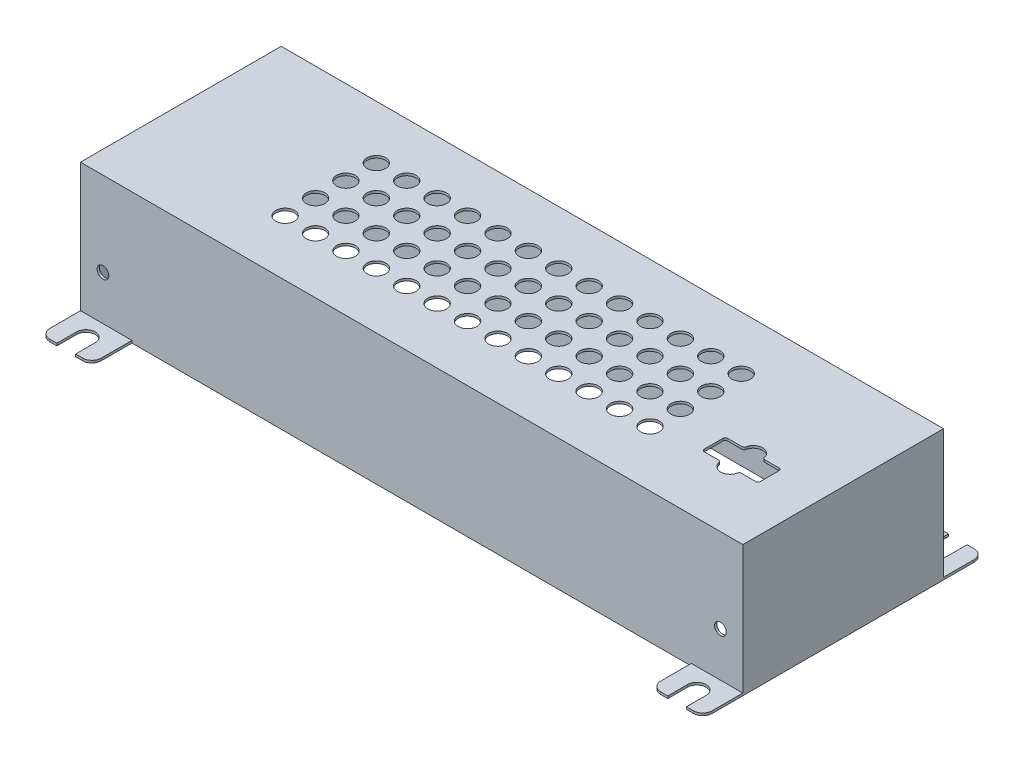
from build123d import *

# Parameters (mm, degrees)
SCHIZZO1_W                   = 141.6
SCHIZZO1_H                   = 42.9
ESTRUSIONE_ESTRUSIONE1_DEPTH = 28
SVUOTA1_T                    = -0.5
RIPETIZIONE_A_L1_COUNT       = 13
RIPETIZIONE_A_L1_PITCH       = 6.5
RIPETIZIONE_A_L1_COUNT_DIR2  = 4
RIPETIZIONE_A_L1_PITCH_DIR2  = 6.5
SCHIZZO4_W                   = 12
SCHIZZO4_H                   = 5
TAGLIO_ESTRUSIONE1_DEPTH     = 28
TAGLIO_ESTRUSIONE2_DEPTH     = 28
SCHIZZO8_W                   = 11
SCHIZZO8_H                   = 8.55
ESTRUSIONE_ESTRUSIONE2_DEPTH = 0.5
TAGLIO_ESTRUSIONE3_DEPTH     = 10
RIPETIZIONE_A_L2_COUNT       = 2
RIPETIZIONE_A_L2_PITCH       = 130.6
FORO_FILETTATO_M3X0_5_1_D    = 2.5
RACCORDO2_R                  = 2
RACCORDO3_R                  = 0.5


with BuildPart() as part:
    # Schizzo1 → Estrusione-Estrusione1 (new body)
    with BuildSketch(Plane(origin=(0, 0, 0), x_dir=(1, 0, 0), z_dir=(0, 1, 0))):
        Rectangle(SCHIZZO1_W, SCHIZZO1_H)
    extrude(amount=ESTRUSIONE_ESTRUSIONE1_DEPTH)

    # Svuota1
    svuota1_openings = [part.faces().sort_by_distance(p)[0] for p in [
        (0, 0, 0),
    ]]
    offset(amount=SVUOTA1_T, openings=svuota1_openings, kind=Kind.INTERSECTION)

    # Schizzo2 → Foro Ø4.0 (4)-1 (revolve, cut)
    with BuildSketch(Plane(origin=(-39, 28, -10), x_dir=(0, 0, 1), z_dir=(1, 0, 0))):
        Polygon((0, 0), (0, 7.201721238), (2, 6), (2, 0), align=None)
    foro_4_0_4_1 = revolve(axis=Axis((-39, 34.35, -10), (0, -1, 0)), mode=Mode.SUBTRACT)

    # Ripetizione a L1: Foro _4.0 _4_-1 13 × 4
    with Locations(*[(i * RIPETIZIONE_A_L1_PITCH, 0, j * RIPETIZIONE_A_L1_PITCH_DIR2) for i in range(RIPETIZIONE_A_L1_COUNT) for j in range(RIPETIZIONE_A_L1_COUNT_DIR2) if (i, j) != (0, 0)]):
        add(foro_4_0_4_1, mode=Mode.SUBTRACT)

    # Schizzo4 → Taglio-Estrusione1 (cut)
    with BuildSketch(Plane(origin=(0, 28, 0), x_dir=(1, 0, 0), z_dir=(0, 1, 0))):
        with Locations((55, -5.9)):
            Rectangle(SCHIZZO4_W, SCHIZZO4_H)
    extrude(amount=-TAGLIO_ESTRUSIONE1_DEPTH, mode=Mode.SUBTRACT)

    # Schizzo6 → Taglio-Estrusione2 (cut)
    with BuildSketch(Plane(origin=(0, 28, 0), x_dir=(1, 0, 0), z_dir=(0, 1, 0))):
        with BuildLine():
            Line((53, -3.4), (57, -3.4))
            ThreePointArc((57, -3.4), (55, -1.4), (53, -3.4))
        make_face()
        with BuildLine():
            Line((57, -8.4), (53, -8.4))
            ThreePointArc((53, -8.4), (55, -10.4), (57, -8.4))
        make_face()
    extrude(amount=-TAGLIO_ESTRUSIONE2_DEPTH, mode=Mode.SUBTRACT)

    # Schizzo8 → Estrusione-Estrusione2 (add)
    with BuildSketch(Plane(origin=(0, 0, 0), x_dir=(1, 0, 0), z_dir=(0, 1, 0))):
        with Locations((-65.3, 25.725)):
            Rectangle(SCHIZZO8_W, SCHIZZO8_H)
        with Locations((-65.3, -25.725)):
            Rectangle(SCHIZZO8_W, SCHIZZO8_H)
    estrusione_estrusione2 = extrude(amount=ESTRUSIONE_ESTRUSIONE2_DEPTH)

    # Schizzo9 → Taglio-Estrusione3 (cut)
    with BuildSketch(Plane(origin=(0, 0.5, 0), x_dir=(1, 0, 0), z_dir=(0, 1, 0))):
        with BuildLine():
            Line((-67.3, 30), (-63.3, 30))
            Line((-63.3, 30), (-63.3, 25.8))
            ThreePointArc((-63.3, 25.8), (-65.3, 23.8), (-67.3, 25.8))
            Line((-67.3, 25.8), (-67.3, 30))
        make_face()
        with BuildLine():
            Line((-67.3, -30), (-63.3, -30))
            Line((-63.3, -30), (-63.3, -25.8))
            ThreePointArc((-63.3, -25.8), (-65.3, -23.8), (-67.3, -25.8))
            Line((-67.3, -25.8), (-67.3, -30))
        make_face()
    taglio_estrusione3 = extrude(amount=-TAGLIO_ESTRUSIONE3_DEPTH, mode=Mode.SUBTRACT)

    # Ripetizione a L2: Estrusione-Estrusione2, Taglio-Estrusione3 ×2
    with Locations(*[(i * RIPETIZIONE_A_L2_PITCH, 0, 0) for i in range(1, RIPETIZIONE_A_L2_COUNT)]):
        add(estrusione_estrusione2)
        add(taglio_estrusione3, mode=Mode.SUBTRACT)

    # Foro filettato M3x0.5-1 (through all)
    with Locations(Plane.XY.offset(21.45)):
        with Locations((-66, 10), (66, 10)):
            Hole(FORO_FILETTATO_M3X0_5_1_D / 2)

    # Raccordo2
    raccordo2_edges = [part.edges().sort_by_distance(p)[0] for p in [
        (-59.8, 0.25, -30),
        (-70.8, 0.25, -30),
        (-70.8, 0.25, 30),
        (-59.8, 0.25, 30),
        (59.8, 0.25, -30),
        (70.8, 0.25, -30),
        (59.8, 0.25, 30),
        (70.8, 0.25, 30),
    ]]
    fillet(raccordo2_edges, radius=RACCORDO2_R)

    # Raccordo3
    raccordo3_edges = [part.edges().sort_by_distance(p)[0] for p in [
        (61, 27.75, 3.4),
        (61, 27.75, 8.4),
        (49, 27.75, 8.4),
        (49, 27.75, 3.4),
        (57, 27.75, 3.4),
        (53, 27.75, 3.4),
        (53, 27.75, 8.4),
        (57, 27.75, 8.4),
    ]]
    fillet(raccordo3_edges, radius=RACCORDO3_R)


solid = part.part
